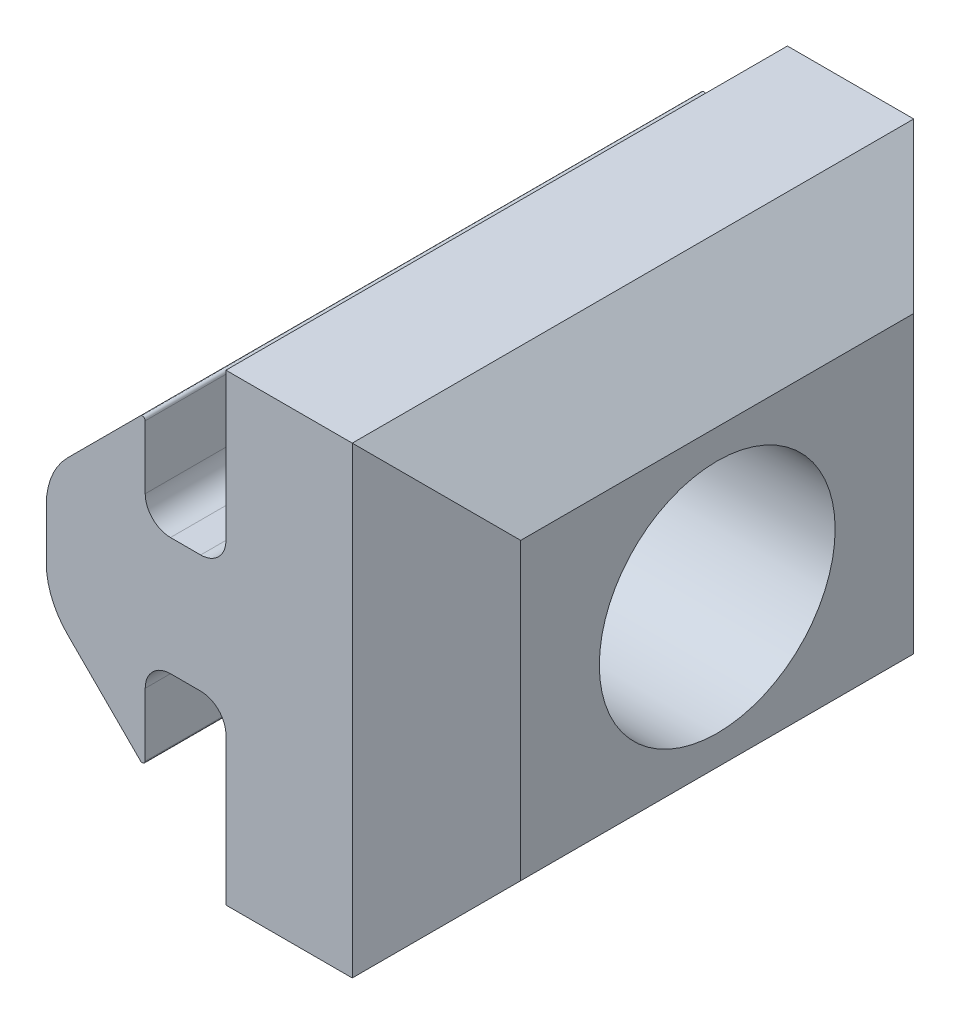
from build123d import *

# Parameters (mm, degrees)
BOSS_EXTRUDE1_DEPTH = 20
CHAMFER1_SIZE       = 3
CUT_EXTRUDE1_START  = 1.014174
SKETCH2_R           = 4.2
CUT_EXTRUDE1_DEPTH  = 6


with BuildPart() as part:
    # Sketch1 → Boss-Extrude1 (new body)
    with BuildSketch(Plane.XY):
        with BuildLine():
            Line((-1.385825984, -1.366427285), (-2.461204781, -1.366427285))
            ThreePointArc((-2.461204781, -1.366427285), (-3.097600884, -1.630031182), (-3.361204781, -2.266427285))
            Line((-3.361204781, -2.266427285), (-3.361204781, -4.516427285))
            ThreePointArc((-3.361204781, -4.516427285), (-3.422936438, -4.608815239), (-3.531915459, -4.587137963))
            Line((-3.531915459, -4.587137963), (-6.124303615, -1.994749808))
            ThreePointArc((-6.124303615, -1.994749808), (-6.687912768, -1.151249101), (-6.885825984, -0.156272177))
            Line((-6.885825984, -0.156272177), (-6.885825984, 1.623417606))
            ThreePointArc((-6.885825984, 1.623417606), (-6.687912768, 2.61839453), (-6.124303615, 3.461895237))
            Line((-6.124303615, 3.461895237), (-3.531915459, 6.054283393))
            ThreePointArc((-3.531915459, 6.054283393), (-3.422936438, 6.075960668), (-3.361204781, 5.983572715))
            Line((-3.361204781, 5.983572715), (-3.361204781, 3.733572715))
            ThreePointArc((-3.361204781, 3.733572715), (-3.097600884, 3.097176612), (-2.461204781, 2.833572715))
            Line((-2.461204781, 2.833572715), (-1.385825984, 2.833572715))
            ThreePointArc((-1.385825984, 2.833572715), (-0.749429881, 3.097176612), (-0.485825984, 3.733572715))
            Line((-0.485825984, 3.733572715), (-0.485825984, 8.983572715))
            Line((-0.485825984, 8.983572715), (7.014174016, 8.983572715))
            Line((7.014174016, 8.983572715), (7.014174016, -7.516427285))
            Line((7.014174016, -7.516427285), (-0.485825984, -7.516427285))
            Line((-0.485825984, -7.516427285), (-0.485825984, -2.266427285))
            ThreePointArc((-0.485825984, -2.266427285), (-0.749429881, -1.630031182), (-1.385825984, -1.366427285))
        make_face()
    extrude(amount=BOSS_EXTRUDE1_DEPTH)

    # Chamfer1
    chamfer1_edges = [part.edges().sort_by_distance(p)[0] for p in [
        (7.014174016, 0.733572715, 20),
        (7.014174016, 0.733572715, 0),
        (7.014174016, 8.983572715, 10),
        (7.014174016, -7.516427285, 10),
    ]]
    chamfer(chamfer1_edges, length=CHAMFER1_SIZE)

    # Sketch2 (on Right Plane) → Cut-Extrude1 (cut)
    with BuildSketch(Plane(origin=(0, 0, 0), x_dir=(0, 0, -1), z_dir=(1, 0, 0)).offset(CUT_EXTRUDE1_START)):
        with Locations((-10, 0.733572715)):
            Circle(SKETCH2_R)
    extrude(amount=CUT_EXTRUDE1_DEPTH, mode=Mode.SUBTRACT)


solid = part.part
